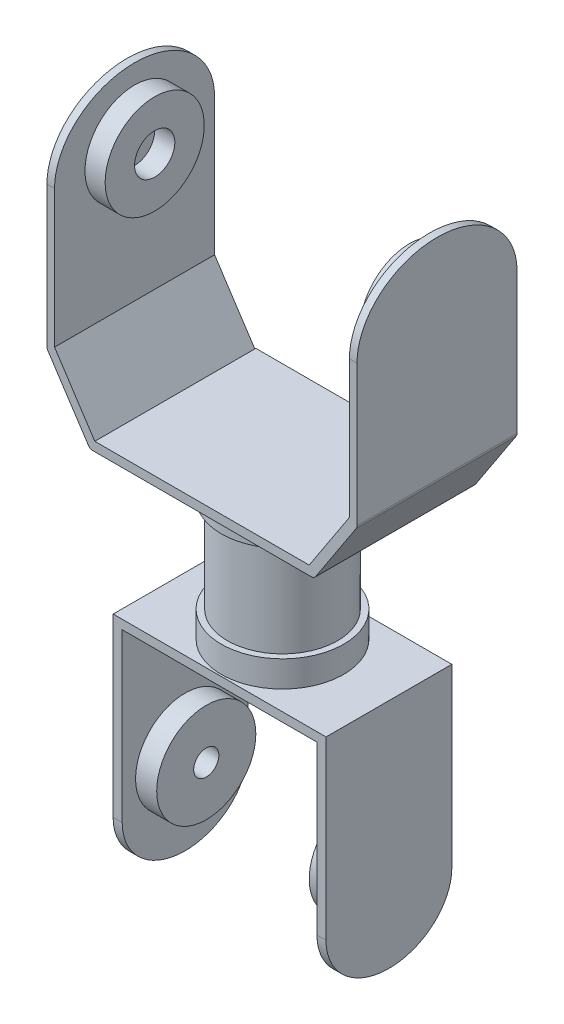
from build123d import *

# Parameters (mm, degrees)
SKETCH2_W            = 42.6
SKETCH2_H            = 32
BOSS_EXTRUDE1_DEPTH  = 1.8
BOSS_EXTRUDE2_DEPTH  = 31.8
FILLET1_R            = 1
SKETCH4_W            = 1.505239861
SKETCH4_H            = 31.8
BOSS_EXTRUDE3_DEPTH  = 41
CUT_EXTRUDE1_DEPTH   = 41
SKETCH7_R            = 9.85
SKETCH7_R_2          = 4
BOSS_EXTRUDE4_DEPTH  = 4
FILLET1_OF_MIRROR2_R = 1
SKETCH8_R            = 12.15
BOSS_EXTRUDE5_DEPTH  = 5.4
SKETCH9_R            = 10.95
BOSS_EXTRUDE6_DEPTH  = 19
SKETCH11_R           = 12.15
BOSS_EXTRUDE7_DEPTH  = 5.2
SKETCH12_W           = 42.3
SKETCH12_H           = 25
BOSS_EXTRUDE8_DEPTH  = 1.8
SKETCH13_W           = 1.8
SKETCH13_H           = 25
BOSS_EXTRUDE9_DEPTH  = 44.3
CUT_EXTRUDE5_DEPTH   = 44.3
SKETCH18_R           = 9.85
SKETCH18_R_2         = 2.5
BOSS_EXTRUDE10_DEPTH = 4.2


with BuildPart() as part:
    # Sketch2 → Boss-Extrude1 (new body)
    with BuildSketch(Plane(origin=(0, 0, 0), x_dir=(1, 0, 0), z_dir=(0, 1, 0))):
        Rectangle(SKETCH2_W, SKETCH2_H)
    extrude(amount=BOSS_EXTRUDE1_DEPTH)

    # Sketch3 → Boss-Extrude2 (add)
    with BuildSketch(Plane.XY.offset(16)):
        Polygon((21.3, 1.8), (29.3, 14), (30.805239861, 14), (30.805239861, 13.012957468), (22.272152997, 0), (21.3, 0), align=None)
    boss_extrude2 = extrude(amount=-BOSS_EXTRUDE2_DEPTH)

    # Fillet1
    fillet1_edges = [part.edges().sort_by_distance(p)[0] for p in [
        (30.805239861, 13.012957468, 0.1),
        (22.272152997, 0, 0.1),
    ]]
    fillet(fillet1_edges, radius=FILLET1_R)

    # Sketch4 → Boss-Extrude3 (add)
    with BuildSketch(Plane(origin=(0, 14, 0), x_dir=(1, 0, 0), z_dir=(0, 1, 0))):
        with Locations((30.052619931, -0.1)):
            Rectangle(SKETCH4_W, SKETCH4_H)
    boss_extrude3 = extrude(amount=BOSS_EXTRUDE3_DEPTH)

    # Sketch5 → Cut-Extrude1 (cut)
    with BuildSketch(Plane(origin=(30.805239861, 0, 0), x_dir=(0, 0, -1), z_dir=(1, 0, 0))):
        with BuildLine():
            Line((-16, 55), (-16, 41.31158709))
            add(Edge.make_bspline(
                [(-0.1, 55), (-16, 55), (-16, 41.31158709)],
                knots=[1.570796327, 1.570796327, 1.570796327, 3.141592654, 3.141592654, 3.141592654], degree=2, weights=[1, 0.707106781, 1]))
            Line((-0.1, 55), (-16, 55))
        make_face()
        with BuildLine():
            Line((15.8, 55), (-0.1, 55))
            add(Edge.make_bspline(
                [(15.8, 41.31158709), (15.8, 55), (-0.1, 55)],
                knots=[0, 0, 0, 1.570796327, 1.570796327, 1.570796327], degree=2, weights=[1, 0.707106781, 1]))
            Line((15.8, 41.31158709), (15.8, 55))
        make_face()
    cut_extrude1 = extrude(amount=-CUT_EXTRUDE1_DEPTH, mode=Mode.SUBTRACT)

    # Sketch7 → Boss-Extrude4 (add)
    with BuildSketch(Plane.ZY.offset(-29.3)):
        with Locations((0.1, 41.31158709)):
            Circle(SKETCH7_R)
        with Locations((0.1, 41.31158709)):
            Circle(SKETCH7_R_2, mode=Mode.SUBTRACT)
    boss_extrude4 = extrude(amount=BOSS_EXTRUDE4_DEPTH)

    # Mirror2: Boss-Extrude2, Boss-Extrude3, Cut-Extrude1, Boss-Extrude4 across plane
    add(boss_extrude2.mirror(Plane(origin=(0, 0, 0), x_dir=(0, 0, 1), z_dir=(1, 0, 0))))
    add(boss_extrude3.mirror(Plane(origin=(0, 0, 0), x_dir=(0, 0, 1), z_dir=(1, 0, 0))))
    add(cut_extrude1.mirror(Plane(origin=(0, 0, 0), x_dir=(0, 0, 1), z_dir=(1, 0, 0))), mode=Mode.SUBTRACT)
    add(boss_extrude4.mirror(Plane(origin=(0, 0, 0), x_dir=(0, 0, 1), z_dir=(1, 0, 0))))

    # Fillet1 of Mirror2
    fillet1_of_mirror2_edges = [part.edges().sort_by_distance(p)[0] for p in [
        (-30.805239861, 13.012957468, 0.1),
        (-22.272152997, 0, 0.1),
    ]]
    fillet(fillet1_of_mirror2_edges, radius=FILLET1_OF_MIRROR2_R)

    # Sketch8 → Boss-Extrude5 (add)
    with BuildSketch(Plane.XZ):
        Circle(SKETCH8_R)
    extrude(amount=BOSS_EXTRUDE5_DEPTH)

    # Sketch9 → Boss-Extrude6 (add)
    with BuildSketch(Plane.XZ.offset(5.4)):
        Circle(SKETCH9_R)
    extrude(amount=BOSS_EXTRUDE6_DEPTH)

    # Sketch11 → Boss-Extrude7 (add)
    with BuildSketch(Plane.XZ.offset(24.4)):
        Circle(SKETCH11_R)
    extrude(amount=BOSS_EXTRUDE7_DEPTH)

    # Sketch12 → Boss-Extrude8 (add)
    with BuildSketch(Plane.XZ.offset(29.6)):
        Rectangle(SKETCH12_W, SKETCH12_H)
    extrude(amount=BOSS_EXTRUDE8_DEPTH)

    # Sketch13 → Boss-Extrude9 (add)
    with BuildSketch(Plane.XZ.offset(31.4)):
        with Locations((-20.25, 0)):
            Rectangle(SKETCH13_W, SKETCH13_H)
    boss_extrude9 = extrude(amount=BOSS_EXTRUDE9_DEPTH)

    # Sketch16 → Cut-Extrude5 (cut)
    with BuildSketch(Plane.ZY.offset(21.15)):
        with BuildLine():
            add(Edge.make_bspline(
                [(-12.5, -64.6), (-12.5, -75.7), (0, -75.7)],
                knots=[3.141592654, 3.141592654, 3.141592654, 4.71238898, 4.71238898, 4.71238898], degree=2, weights=[1, 0.707106781, 1]))
            Line((-12.5, -64.6), (-12.5, -75.7))
            Line((-12.5, -75.7), (3.5e-08, -75.7))
        make_face()
        with BuildLine():
            Line((12.5, -75.7), (12.5, -64.6))
            add(Edge.make_bspline(
                [(3.5e-08, -75.7), (12.5, -75.699999969), (12.5, -64.6)],
                knots=[4.712388984, 4.712388984, 4.712388984, 6.283185307, 6.283185307, 6.283185307], degree=2, weights=[0.999999999, 0.707106782, 1]))
            Line((3.5e-08, -75.7), (12.5, -75.7))
        make_face()
    cut_extrude5 = extrude(amount=-CUT_EXTRUDE5_DEPTH, mode=Mode.SUBTRACT)

    # Sketch18 → Boss-Extrude10 (add)
    with BuildSketch(Plane(origin=(-19.35, 0, 0), x_dir=(0, 0, -1), z_dir=(1, 0, 0))):
        with Locations((0, -58.4)):
            Circle(SKETCH18_R)
        with Locations((0, -58.4)):
            Circle(SKETCH18_R_2, mode=Mode.SUBTRACT)
    boss_extrude10 = extrude(amount=BOSS_EXTRUDE10_DEPTH)

    # Mirror3: Boss-Extrude9, Cut-Extrude5, Boss-Extrude10 across plane
    add(boss_extrude9.mirror(Plane(origin=(0, 0, 0), x_dir=(0, 0, 1), z_dir=(1, 0, 0))))
    add(cut_extrude5.mirror(Plane(origin=(0, 0, 0), x_dir=(0, 0, 1), z_dir=(1, 0, 0))), mode=Mode.SUBTRACT)
    add(boss_extrude10.mirror(Plane(origin=(0, 0, 0), x_dir=(0, 0, 1), z_dir=(1, 0, 0))))


solid = part.part
